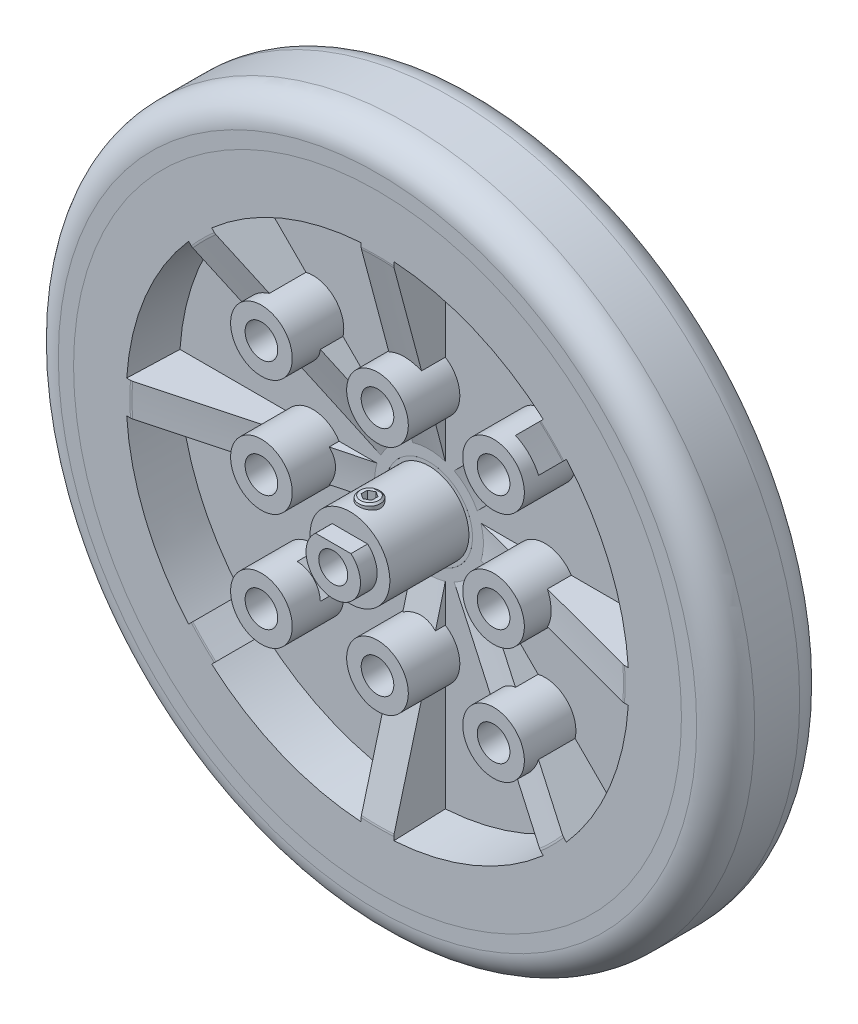
from build123d import *

# Parameters (mm, degrees)
SKETCH5_R               = 1.25
CUT_EXTRUDE1_DEPTH      = 7
SKETCH6_W               = 4.874423042
SKETCH6_H               = 1.8
CUT_EXTRUDE2_DEPTH      = 3.3000001
SKETCH1_R               = 34.4
SKETCH1_R_2             = 6
BOSS_EXTRUDE1_DEPTH     = 7.1
SKETCH7_R               = 1.5
BOSS_EXTRUDE3_DEPTH     = 4.6
CHAMFER1_SIZE           = 0.25
CUT_EXTRUDE3_DEPTH      = 2
BOSS_EXTRUDE4_DEPTH     = 7.1
CIRPATTERN1_COUNT       = 8
FILLET1_R               = 1
SKETCH13_R              = 4.25
BOSS_EXTRUDE5_DEPTH     = 14.2
SKETCH14_R              = 2.25
CUT_EXTRUDE4_DEPTH      = 15.7000001
LPATTERN1_COUNT         = 3
LPATTERN1_PITCH         = 16
LPATTERN1_COUNT_DIR2    = 3
LPATTERN1_PITCH_DIR2    = 16
CUT_EXTRUDE5_DEPTH      = 2
CIRPATTERN2_COUNT       = 8
SKETCH16_W              = 0.5
SKETCH16_H              = 29.882140073
SKETCH16_W_2            = 29.882140073
SKETCH16_H_2            = 0.5
CUT_EXTRUDE_THIN2_DEPTH = 0.2
SKETCH18_R              = 40.5
SKETCH18_R_2            = 39
CUT_EXTRUDE6_DEPTH      = 1
FILLET2_R               = 4


with BuildPart() as part:
    # Sketch4 → Revolve1 (revolve)
    with BuildSketch(Plane(origin=(0, 0, 0), x_dir=(1, 0, 0), z_dir=(0, 1, 0))):
        Polygon((2, 0.5), (2, -20.3), (3.75, -20.3), (3.75, -18), (5.5, -18), (5.5, -7.1), (6, -7.1), (6, 0), (5.5, 0), (5.5, 0.5), align=None)
    revolve(axis=Axis((0, 0, -23.226019237), (0, 0, 1)))

    # Sketch5 → Cut-Extrude1 (cut, through all)
    with BuildSketch(Plane(origin=(0, 0, 0), x_dir=(1, 0, 0), z_dir=(0, 1, 0))):
        with Locations((0, -15.3)):
            Circle(SKETCH5_R)
    extrude(amount=CUT_EXTRUDE1_DEPTH, mode=Mode.SUBTRACT)

    # Sketch6 → Cut-Extrude2 (cut, through all)
    with BuildSketch(Plane.XY.offset(18)):
        with Locations((0, 3.75)):
            Rectangle(SKETCH6_W, SKETCH6_H)
    extrude(amount=CUT_EXTRUDE2_DEPTH, mode=Mode.SUBTRACT)


with BuildPart() as body_2:
    # Sketch1 → Boss-Extrude1 (new body)
    with BuildSketch(Plane.XY):
        Circle(SKETCH1_R)
        Circle(SKETCH1_R_2, mode=Mode.SUBTRACT)
    extrude(amount=BOSS_EXTRUDE1_DEPTH)


with BuildPart() as body_3:
    # Sketch7 → Boss-Extrude3 (new body)
    with BuildSketch(Plane(origin=(0, 1.5, 0), x_dir=(1, 0, 0), z_dir=(0, 1, 0))):
        with Locations((0, -15.3)):
            Circle(SKETCH7_R)
    extrude(amount=BOSS_EXTRUDE3_DEPTH)

    # Chamfer1
    chamfer1_edges = [body_3.edges().sort_by_distance(p)[0] for p in [
        (-1.5, 6.1, 15.3),
    ]]
    chamfer(chamfer1_edges, length=CHAMFER1_SIZE)

    # Sketch8 → Cut-Extrude3 (cut)
    with BuildSketch(Plane(origin=(0, 6.1, 0), x_dir=(1, 0, 0), z_dir=(0, 1, 0))):
        Polygon((0.039678694, -14.434884053), (-0.72937304, -14.833079269), (-0.769051734, -15.698195216), (-0.039678694, -16.165115947), (0.72937304, -15.766920731), (0.769051734, -14.901804784), align=None)
    extrude(amount=-CUT_EXTRUDE3_DEPTH, mode=Mode.SUBTRACT)


with BuildPart() as body_4:
    # Sketch9 → Revolve2 (revolve)
    with BuildSketch(Plane(origin=(0, 0, 0), x_dir=(1, 0, 0), z_dir=(0, 1, 0))):
        Polygon((34.4, 0), (34.4, -7.1), (34.647937463, -14.2), (41.9, -14.2), (41.9, -11.2), (38.4, -11.2), (38.4, -3), (41.9, -3), (41.9, 0), align=None)
    revolve(axis=Axis((0, 0, -13.352718611), (0, 0, 1)))


with BuildPart() as body_2_1:
    add(body_2.part)

    # Combine1: union body 4
    add(body_4.part)


with BuildPart() as body_4_2:
    # Sketch10 → Boss-Extrude4 (new body)
    with BuildSketch(Plane.XY.offset(7.1)):
        with BuildLine():
            Line((-2.25, 34.574803983), (-2.25, 6.628536792))
            ThreePointArc((-2.25, 6.628536792), (0, 7), (2.25, 6.628536792))
            Line((2.25, 6.628536792), (2.25, 34.574803983))
            ThreePointArc((2.25, 34.574803983), (0, 34.647937463), (-2.25, 34.574803983))
        make_face()
    extrude(amount=BOSS_EXTRUDE4_DEPTH)


with BuildPart() as cirpattern1_1:
    # CirPattern1: pattern copy
    add(body_4_2.part.rotate(Axis((0, 0, 0), (0, 0, 1)), 1 * 360 / CIRPATTERN1_COUNT))


with BuildPart() as cirpattern1_2:
    # CirPattern1: pattern copy
    add(body_4_2.part.rotate(Axis((0, 0, 0), (0, 0, 1)), 2 * 360 / CIRPATTERN1_COUNT))


with BuildPart() as cirpattern1_3:
    # CirPattern1: pattern copy
    add(body_4_2.part.rotate(Axis((0, 0, 0), (0, 0, 1)), 3 * 360 / CIRPATTERN1_COUNT))


with BuildPart() as cirpattern1_4:
    # CirPattern1: pattern copy
    add(body_4_2.part.rotate(Axis((0, 0, 0), (0, 0, 1)), 4 * 360 / CIRPATTERN1_COUNT))


with BuildPart() as cirpattern1_5:
    # CirPattern1: pattern copy
    add(body_4_2.part.rotate(Axis((0, 0, 0), (0, 0, 1)), 5 * 360 / CIRPATTERN1_COUNT))


with BuildPart() as cirpattern1_6:
    # CirPattern1: pattern copy
    add(body_4_2.part.rotate(Axis((0, 0, 0), (0, 0, 1)), 6 * 360 / CIRPATTERN1_COUNT))


with BuildPart() as cirpattern1_7:
    # CirPattern1: pattern copy
    add(body_4_2.part.rotate(Axis((0, 0, 0), (0, 0, 1)), 7 * 360 / CIRPATTERN1_COUNT))


with BuildPart() as body_2_2:
    add(body_2_1.part)

    # Combine2: union body 4 2, CirPattern1_1, CirPattern1_2, CirPattern1_3, CirPattern1_4, CirPattern1_5, CirPattern1_6, CirPattern1_7
    add(body_4_2.part)
    add(cirpattern1_1.part)
    add(cirpattern1_2.part)
    add(cirpattern1_3.part)
    add(cirpattern1_4.part)
    add(cirpattern1_5.part)
    add(cirpattern1_6.part)
    add(cirpattern1_7.part)


with BuildPart() as cut_revolve1_tool:
    # Sketch12 → Cut-Revolve1 (revolve)
    with BuildSketch(Plane(origin=(0, 0, 0), x_dir=(1, 0, 0), z_dir=(0, 1, 0))):
        Polygon((7.5, -7.1), (34, -14.2), (6, -14.2), (6, -7.1), align=None)
    revolve(axis=Axis((0, 0, 23.246192907), (0, 0, -1)))


with BuildPart() as body_2_3:
    add(body_2_2.part)

    # Cut-Revolve1: cut by cut_revolve1_tool
    add(cut_revolve1_tool.part, mode=Mode.SUBTRACT)

    # Fillet1
    fillet1_edges = [body_2_3.edges().sort_by_distance(p)[0] for p in [
        (0, 34, 14.2),
        (-24.04163056, 24.04163056, 14.2),
        (-34, 0, 14.2),
        (-24.04163056, -24.04163056, 14.2),
        (0, -34, 14.2),
        (24.04163056, -24.04163056, 14.2),
        (34, 0, 14.2),
        (24.04163056, 24.04163056, 14.2),
    ]]
    fillet(fillet1_edges, radius=FILLET1_R)

    # Sketch13 → Boss-Extrude5 (add)
    with BuildSketch(Plane.XY.offset(14.2)):
        with Locations((-16, 16)):
            Circle(SKETCH13_R)
    boss_extrude5 = extrude(amount=-BOSS_EXTRUDE5_DEPTH)

    # Sketch14 → Cut-Extrude4 (cut, through all)
    with BuildSketch(Plane.XY.offset(14.2)):
        with Locations((-16, 16)):
            Circle(SKETCH14_R)
    cut_extrude4 = extrude(amount=-CUT_EXTRUDE4_DEPTH, mode=Mode.SUBTRACT)

    # LPattern1: Boss-Extrude5, Cut-Extrude4 3 × 3, 1 skipped
    with Locations(*[(i * LPATTERN1_PITCH, -j * LPATTERN1_PITCH_DIR2, 0) for i in range(LPATTERN1_COUNT) for j in range(LPATTERN1_COUNT_DIR2) if (i, j) not in ((0, 0), (1, 1))]):
        add(boss_extrude5)
        add(cut_extrude4, mode=Mode.SUBTRACT)

    # Sketch15 → Cut-Extrude5 (cut)
    with BuildSketch(Plane(origin=(0, 0, 0), x_dir=(-1, 0, 0), z_dir=(0, 0, -1))):
        with BuildLine():
            Line((2.5, 37.917673979), (2.5, 6.035533906))
            Line((2.5, 6.035533906), (25.044077445, 28.579611351))
            ThreePointArc((25.044077445, 28.579611351), (14.54197043, 35.107422235), (2.5, 37.917673979))
        make_face()
    cut_extrude5 = extrude(amount=-CUT_EXTRUDE5_DEPTH, mode=Mode.SUBTRACT)

    # CirPattern2: Cut-Extrude5 ×8 about axis
    cirpattern2_axis = Axis((0, 0, 0), (0, 0, 1))
    for i in range(1, CIRPATTERN2_COUNT):
        add(cut_extrude5.rotate(cirpattern2_axis, i * 360 / CIRPATTERN2_COUNT), mode=Mode.SUBTRACT)

    # Sketch16 → Cut-Extrude-Thin2 (cut)
    with BuildSketch(Plane(origin=(0, 0, 0), x_dir=(-1, 0, 0), z_dir=(0, 0, -1))):
        with Locations((0.25, 21.976603942)):
            Rectangle(SKETCH16_W, SKETCH16_H)
        with Locations((1.25, 21.976603942)):
            Rectangle(SKETCH16_W, SKETCH16_H)
        with Locations((-0.75, 21.976603942)):
            Rectangle(SKETCH16_W, SKETCH16_H)
        Polygon((4.267766953, 5.681980515), (25.397630835, 26.811844398), (25.751184226, 26.458291007), (4.621320344, 5.328427125), align=None)
        Polygon((4.974873734, 4.974873734), (26.104737616, 26.104737616), (26.458291007, 25.751184226), (5.328427125, 4.621320344), align=None)
        Polygon((5.681980515, 4.267766953), (26.811844398, 25.397630835), (27.165397788, 25.044077445), (6.035533906, 3.914213562), align=None)
        with Locations((21.976603942, 0.75)):
            Rectangle(SKETCH16_W_2, SKETCH16_H_2)
        with Locations((21.976603942, -0.25)):
            Rectangle(SKETCH16_W_2, SKETCH16_H_2)
        with Locations((21.976603942, -1.25)):
            Rectangle(SKETCH16_W_2, SKETCH16_H_2)
        Polygon((5.681980515, -4.267766953), (26.811844398, -25.397630835), (26.458291007, -25.751184226), (5.328427125, -4.621320344), align=None)
        Polygon((4.974873734, -4.974873734), (26.104737616, -26.104737616), (25.751184226, -26.458291007), (4.621320344, -5.328427125), align=None)
        Polygon((4.267766953, -5.681980515), (25.397630835, -26.811844398), (25.044077445, -27.165397788), (3.914213562, -6.035533906), align=None)
        with Locations((0.75, -21.976603942)):
            Rectangle(SKETCH16_W, SKETCH16_H)
        with Locations((-0.25, -21.976603942)):
            Rectangle(SKETCH16_W, SKETCH16_H)
        with Locations((-1.25, -21.976603942)):
            Rectangle(SKETCH16_W, SKETCH16_H)
        Polygon((-4.267766953, -5.681980515), (-25.397630835, -26.811844398), (-25.751184226, -26.458291007), (-4.621320344, -5.328427125), align=None)
        Polygon((-4.974873734, -4.974873734), (-26.104737616, -26.104737616), (-26.458291007, -25.751184226), (-5.328427125, -4.621320344), align=None)
        Polygon((-5.681980515, -4.267766953), (-26.811844398, -25.397630835), (-27.165397788, -25.044077445), (-6.035533906, -3.914213562), align=None)
        with Locations((-21.976603942, -0.75)):
            Rectangle(SKETCH16_W_2, SKETCH16_H_2)
        with Locations((-21.976603942, 0.25)):
            Rectangle(SKETCH16_W_2, SKETCH16_H_2)
        with Locations((-21.976603942, 1.25)):
            Rectangle(SKETCH16_W_2, SKETCH16_H_2)
        Polygon((-5.681980515, 4.267766953), (-26.811844398, 25.397630835), (-26.458291007, 25.751184226), (-5.328427125, 4.621320344), align=None)
        Polygon((-4.974873734, 4.974873734), (-26.104737616, 26.104737616), (-25.751184226, 26.458291007), (-4.621320344, 5.328427125), align=None)
        Polygon((-4.267766953, 5.681980515), (-25.397630835, 26.811844398), (-25.044077445, 27.165397788), (-3.914213562, 6.035533906), align=None)
    extrude(amount=-CUT_EXTRUDE_THIN2_DEPTH, mode=Mode.SUBTRACT)

    # Sketch18 → Cut-Extrude6 (cut)
    with BuildSketch(Plane(origin=(0, 0, 0), x_dir=(-1, 0, 0), z_dir=(0, 0, -1))):
        Circle(SKETCH18_R)
        Circle(SKETCH18_R_2, mode=Mode.SUBTRACT)
    extrude(amount=-CUT_EXTRUDE6_DEPTH, mode=Mode.SUBTRACT)


with BuildPart() as body_3_1:
    add(body_3.part)

    # Cut-Revolve1: cut by cut_revolve1_tool
    add(cut_revolve1_tool.part, mode=Mode.SUBTRACT)


with BuildPart() as body_4_3:
    # Sketch20 → Revolve3 (revolve)
    with BuildSketch(Plane(origin=(0, 0, 0), x_dir=(1, 0, 0), z_dir=(0, 1, 0))):
        Polygon((41.9, -3), (41.9, 0), (48, 0), (48, -14.2), (41.9, -14.2), (41.9, -11.2), (38.4, -11.2), (38.4, -3), align=None)
    revolve(axis=Axis((0, 0, -17.162538076), (0, 0, 1)))

    # Fillet2
    fillet2_edges = [body_4_3.edges().sort_by_distance(p)[0] for p in [
        (-48, 0, 0),
        (-48, 0, 14.2),
    ]]
    fillet(fillet2_edges, radius=FILLET2_R)


solid = Compound([part.part, body_2_3.part, body_3_1.part, body_4_3.part])
